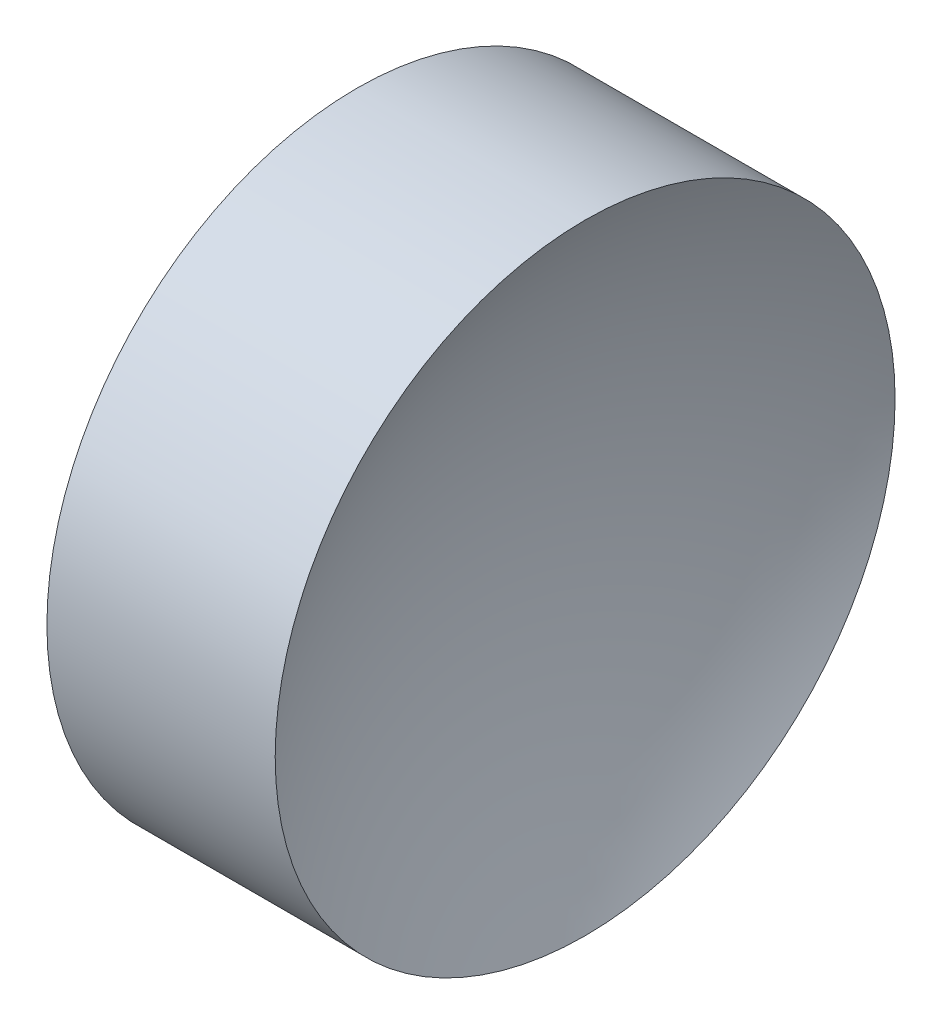
from build123d import *


with BuildPart() as part:
    # 草图1 → 旋转1 (revolve)
    with BuildSketch(Plane.XY, mode=Mode.PRIVATE) as revolve_1_sk:
        with BuildLine():
            Line((22.309268833, 13.031126091), (22.309268833, 16.181126091))
            Line((22.309268833, 16.181126091), (24.629313159, 16.181126091))
            ThreePointArc((24.629313159, 16.181126091), (24.017640499, 14.658622074), (23.809268833, 13.031126091))
            Line((23.809268833, 13.031126091), (22.309268833, 13.031126091))
        make_face()
    revolve(revolve_1_sk.sketch.rotate(Axis((20.684030635, 13.031126091, 0), (1, 0, 0)), 180), axis=Axis((20.684030635, 13.031126091, 0), (1, 0, 0)))  # turned: the seam where the file's is


solid = part.part
